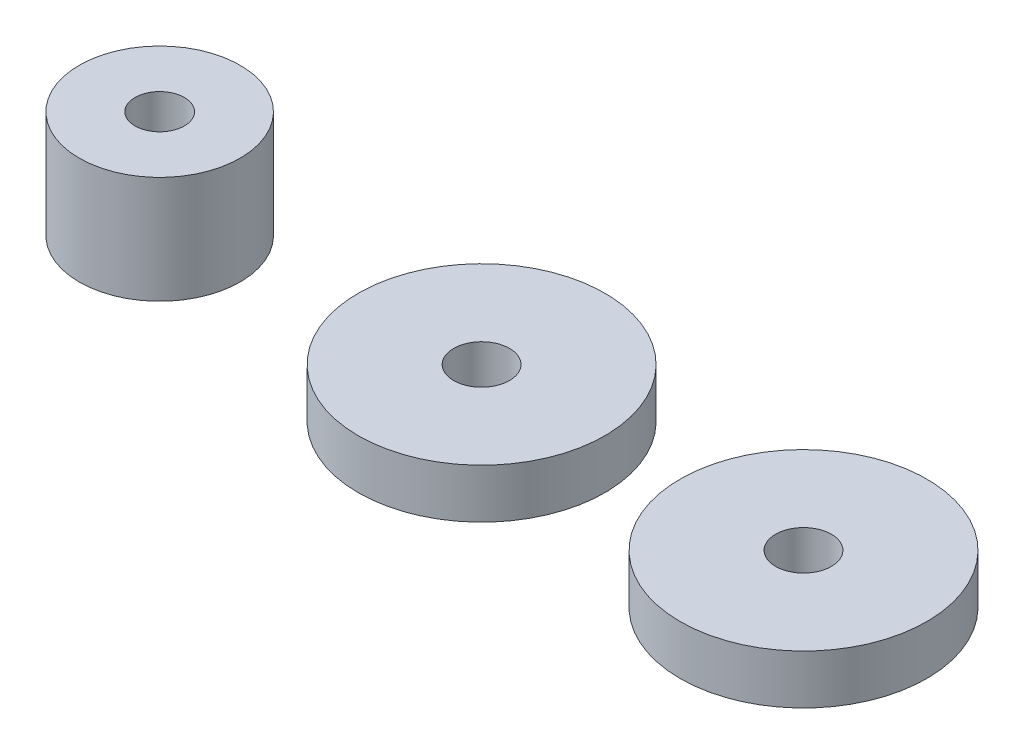
from build123d import *

# Parameters (mm, degrees)
SKETCH1_R             = 3.75
SKETCH1_R_2           = 1.15
BOSS_EXTRUDE1_DEPTH   = 5
SKETCH2_R             = 5.75
SKETCH2_R_2           = 1.3
BOSS_EXTRUDE2_DEPTH   = 2.3
BOSS_EXTRUDE2_2_DEPTH = 2.3


with BuildPart() as part:
    # Sketch1 → Boss-Extrude1 (new body)
    with BuildSketch(Plane(origin=(0, 0, 0), x_dir=(1, 0, 0), z_dir=(0, 1, 0))):
        Circle(SKETCH1_R)
        Circle(SKETCH1_R_2, mode=Mode.SUBTRACT)
    extrude(amount=BOSS_EXTRUDE1_DEPTH)


with BuildPart() as body_2:
    # Sketch2 → Boss-Extrude2 (new body)
    with BuildSketch(Plane(origin=(0, 0, 0), x_dir=(1, 0, 0), z_dir=(0, 1, 0))):
        with Locations((15, 0)):
            Circle(SKETCH2_R)
        with Locations((15, 0)):
            Circle(SKETCH2_R_2, mode=Mode.SUBTRACT)
    extrude(amount=BOSS_EXTRUDE2_DEPTH)


with BuildPart() as body_3:
    # Sketch2 → Boss-Extrude2 2 (new body)
    with BuildSketch(Plane(origin=(0, 0, 0), x_dir=(1, 0, 0), z_dir=(0, 1, 0))):
        with Locations((30, 0)):
            Circle(SKETCH2_R)
        with Locations((30, 0)):
            Circle(SKETCH2_R_2, mode=Mode.SUBTRACT)
    extrude(amount=BOSS_EXTRUDE2_2_DEPTH)


solid = Compound([part.part, body_2.part, body_3.part])
